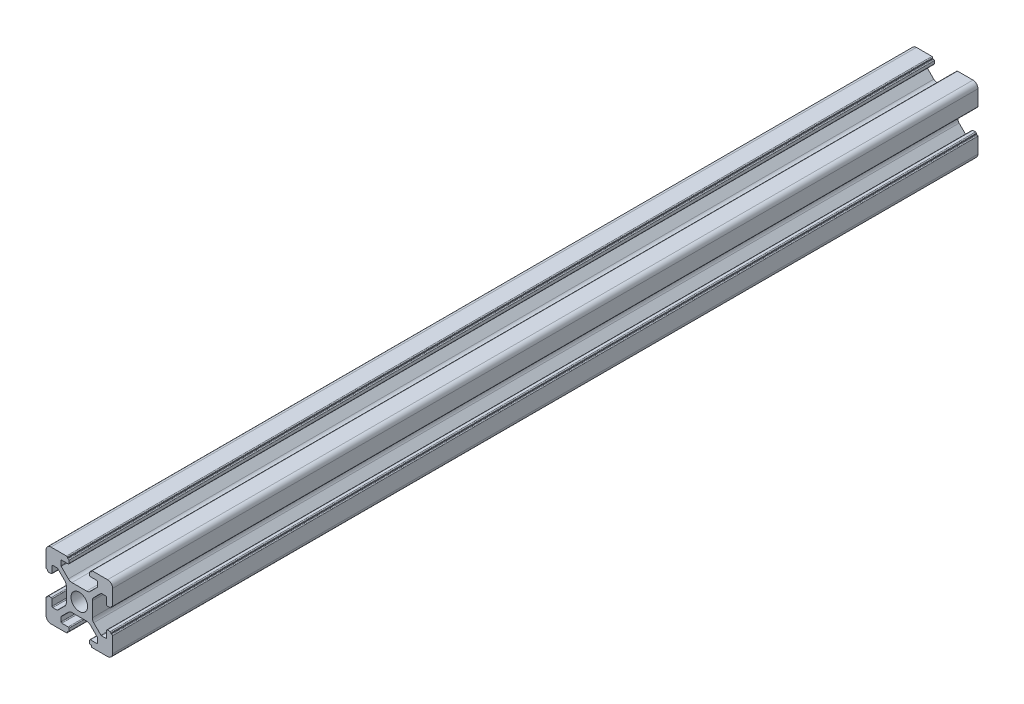
from build123d import *

# Parameters (mm, degrees)
SKETCH_1_R      = 2.5
EXTRUDE_1_DEPTH = 260


with BuildPart() as part:
    # 草图1 → 凸台-拉伸1 (new body)
    with BuildSketch(Plane.XY):
        with BuildLine():
            Line((-8.502261885, -10.002261885), (-3.85, -10.002261885))
            ThreePointArc((-3.85, -10.002261885), (-3.673223305, -9.929038581), (-3.6, -9.752261885))
            Line((-3.6, -9.752261885), (-3.6, -9.502261885))
            Line((-3.6, -9.502261885), (-3.35, -9.502261885))
            ThreePointArc((-3.35, -9.502261885), (-3.173223305, -9.429038581), (-3.1, -9.252261885))
            Line((-3.1, -9.252261885), (-3.1, -8.45))
            ThreePointArc((-3.1, -8.45), (-3.173223305, -8.273223305), (-3.35, -8.2))
            Line((-3.35, -8.2), (-5.25, -8.2))
            ThreePointArc((-5.25, -8.2), (-5.426776695, -8.126776695), (-5.5, -7.95))
            Line((-5.5, -7.95), (-5.5, -6.664213562))
            ThreePointArc((-5.5, -6.664213562), (-5.480969883, -6.568542704), (-5.426776695, -6.487436867))
            Line((-5.426776695, -6.487436867), (-3.278679656, -4.339339828))
            ThreePointArc((-3.278679656, -4.339339828), (-2.792044633, -4.014180701), (-2.218019485, -3.9))
            Line((-2.218019485, -3.9), (2.218019485, -3.9))
            ThreePointArc((2.218019485, -3.9), (2.792044633, -4.014180701), (3.278679656, -4.339339828))
            Line((3.278679656, -4.339339828), (5.426776695, -6.487436867))
            ThreePointArc((5.426776695, -6.487436867), (5.480969883, -6.568542704), (5.5, -6.664213562))
            Line((5.5, -6.664213562), (5.5, -7.95))
            ThreePointArc((5.5, -7.95), (5.426776695, -8.126776695), (5.25, -8.2))
            Line((5.25, -8.2), (3.35, -8.2))
            ThreePointArc((3.35, -8.2), (3.173223305, -8.273223305), (3.1, -8.45))
            Line((3.1, -8.45), (3.1, -9.252261885))
            ThreePointArc((3.1, -9.252261885), (3.173223305, -9.429038581), (3.35, -9.502261885))
            Line((3.35, -9.502261885), (3.6, -9.502261885))
            Line((3.6, -9.502261885), (3.6, -9.752261885))
            ThreePointArc((3.6, -9.752261885), (3.673223305, -9.929038581), (3.85, -10.002261885))
            Line((3.85, -10.002261885), (8.502261885, -10.002261885))
            ThreePointArc((8.502261885, -10.002261885), (9.562922057, -9.562922057), (10.002261885, -8.502261885))
            Line((10.002261885, -8.502261885), (10.002261885, -3.85))
            ThreePointArc((10.002261885, -3.85), (9.929038581, -3.673223305), (9.752261885, -3.6))
            Line((9.752261885, -3.6), (9.502261885, -3.6))
            Line((9.502261885, -3.6), (9.502261885, -3.35))
            ThreePointArc((9.502261885, -3.35), (9.429038581, -3.173223305), (9.252261885, -3.1))
            Line((9.252261885, -3.1), (8.45, -3.1))
            ThreePointArc((8.45, -3.1), (8.273223305, -3.173223305), (8.2, -3.35))
            Line((8.2, -3.35), (8.2, -5.25))
            ThreePointArc((8.2, -5.25), (8.126776695, -5.426776695), (7.95, -5.5))
            Line((7.95, -5.5), (6.664213562, -5.5))
            ThreePointArc((6.664213562, -5.5), (6.568542704, -5.480969883), (6.487436867, -5.426776695))
            Line((6.487436867, -5.426776695), (4.339339828, -3.278679656))
            ThreePointArc((4.339339828, -3.278679656), (4.014180701, -2.792044633), (3.9, -2.218019485))
            Line((3.9, -2.218019485), (3.9, 2.218019485))
            ThreePointArc((3.9, 2.218019485), (4.014180701, 2.792044633), (4.339339828, 3.278679656))
            Line((4.339339828, 3.278679656), (6.487436867, 5.426776695))
            ThreePointArc((6.487436867, 5.426776695), (6.568542704, 5.480969883), (6.664213562, 5.5))
            Line((6.664213562, 5.5), (7.95, 5.5))
            ThreePointArc((7.95, 5.5), (8.126776695, 5.426776695), (8.2, 5.25))
            Line((8.2, 5.25), (8.2, 3.35))
            ThreePointArc((8.2, 3.35), (8.273223305, 3.173223305), (8.45, 3.1))
            Line((8.45, 3.1), (9.252261885, 3.1))
            ThreePointArc((9.252261885, 3.1), (9.429038581, 3.173223305), (9.502261885, 3.35))
            Line((9.502261885, 3.35), (9.502261885, 3.6))
            Line((9.502261885, 3.6), (9.752261885, 3.6))
            ThreePointArc((9.752261885, 3.6), (9.929038581, 3.673223305), (10.002261885, 3.85))
            Line((10.002261885, 3.85), (10.002261885, 8.502261885))
            ThreePointArc((10.002261885, 8.502261885), (9.562922057, 9.562922057), (8.502261885, 10.002261885))
            Line((8.502261885, 10.002261885), (3.85, 10.002261885))
            ThreePointArc((3.85, 10.002261885), (3.673223305, 9.929038581), (3.6, 9.752261885))
            Line((3.6, 9.752261885), (3.6, 9.502261885))
            Line((3.6, 9.502261885), (3.35, 9.502261885))
            ThreePointArc((3.35, 9.502261885), (3.173223305, 9.429038581), (3.1, 9.252261885))
            Line((3.1, 9.252261885), (3.1, 8.45))
            ThreePointArc((3.1, 8.45), (3.173223305, 8.273223305), (3.35, 8.2))
            Line((3.35, 8.2), (5.25, 8.2))
            ThreePointArc((5.25, 8.2), (5.426776695, 8.126776695), (5.5, 7.95))
            Line((5.5, 7.95), (5.5, 6.664213562))
            ThreePointArc((5.5, 6.664213562), (5.480969883, 6.568542704), (5.426776695, 6.487436867))
            Line((5.426776695, 6.487436867), (3.278679656, 4.339339828))
            ThreePointArc((3.278679656, 4.339339828), (2.792044633, 4.014180701), (2.218019485, 3.9))
            Line((2.218019485, 3.9), (-2.218019485, 3.9))
            ThreePointArc((-2.218019485, 3.9), (-2.792044633, 4.014180701), (-3.278679656, 4.339339828))
            Line((-3.278679656, 4.339339828), (-5.426776695, 6.487436867))
            ThreePointArc((-5.426776695, 6.487436867), (-5.480969883, 6.568542704), (-5.5, 6.664213562))
            Line((-5.5, 6.664213562), (-5.5, 7.95))
            ThreePointArc((-5.5, 7.95), (-5.426776695, 8.126776695), (-5.25, 8.2))
            Line((-5.25, 8.2), (-3.35, 8.2))
            ThreePointArc((-3.35, 8.2), (-3.173223305, 8.273223305), (-3.1, 8.45))
            Line((-3.1, 8.45), (-3.1, 9.252261885))
            ThreePointArc((-3.1, 9.252261885), (-3.173223305, 9.429038581), (-3.35, 9.502261885))
            Line((-3.35, 9.502261885), (-3.6, 9.502261885))
            Line((-3.6, 9.502261885), (-3.6, 9.752261885))
            ThreePointArc((-3.6, 9.752261885), (-3.673223305, 9.929038581), (-3.85, 10.002261885))
            Line((-3.85, 10.002261885), (-8.502261885, 10.002261885))
            ThreePointArc((-8.502261885, 10.002261885), (-9.562922057, 9.562922057), (-10.002261885, 8.502261885))
            Line((-10.002261885, 8.502261885), (-10.002261885, 3.85))
            ThreePointArc((-10.002261885, 3.85), (-9.929038581, 3.673223305), (-9.752261885, 3.6))
            Line((-9.752261885, 3.6), (-9.502261885, 3.6))
            Line((-9.502261885, 3.6), (-9.502261885, 3.35))
            ThreePointArc((-9.502261885, 3.35), (-9.429038581, 3.173223305), (-9.252261885, 3.1))
            Line((-9.252261885, 3.1), (-8.45, 3.1))
            ThreePointArc((-8.45, 3.1), (-8.273223305, 3.173223305), (-8.2, 3.35))
            Line((-8.2, 3.35), (-8.2, 5.25))
            ThreePointArc((-8.2, 5.25), (-8.126776695, 5.426776695), (-7.95, 5.5))
            Line((-7.95, 5.5), (-6.664213562, 5.5))
            ThreePointArc((-6.664213562, 5.5), (-6.568542704, 5.480969883), (-6.487436867, 5.426776695))
            Line((-6.487436867, 5.426776695), (-4.339339828, 3.278679656))
            ThreePointArc((-4.339339828, 3.278679656), (-4.014180701, 2.792044633), (-3.9, 2.218019485))
            Line((-3.9, 2.218019485), (-3.9, -2.218019485))
            ThreePointArc((-3.9, -2.218019485), (-4.014180701, -2.792044633), (-4.339339828, -3.278679656))
            Line((-4.339339828, -3.278679656), (-6.487436867, -5.426776695))
            ThreePointArc((-6.487436867, -5.426776695), (-6.568542704, -5.480969883), (-6.664213562, -5.5))
            Line((-6.664213562, -5.5), (-7.95, -5.5))
            ThreePointArc((-7.95, -5.5), (-8.126776695, -5.426776695), (-8.2, -5.25))
            Line((-8.2, -5.25), (-8.2, -3.35))
            ThreePointArc((-8.2, -3.35), (-8.273223305, -3.173223305), (-8.45, -3.1))
            Line((-8.45, -3.1), (-9.252261885, -3.1))
            ThreePointArc((-9.252261885, -3.1), (-9.429038581, -3.173223305), (-9.502261885, -3.35))
            Line((-9.502261885, -3.35), (-9.502261885, -3.6))
            Line((-9.502261885, -3.6), (-9.752261885, -3.6))
            ThreePointArc((-9.752261885, -3.6), (-9.929038581, -3.673223305), (-10.002261885, -3.85))
            Line((-10.002261885, -3.85), (-10.002261885, -8.502261885))
            ThreePointArc((-10.002261885, -8.502261885), (-9.562922057, -9.562922057), (-8.502261885, -10.002261885))
        make_face()
        Circle(SKETCH_1_R, mode=Mode.SUBTRACT)
    extrude(amount=EXTRUDE_1_DEPTH)


solid = part.part
